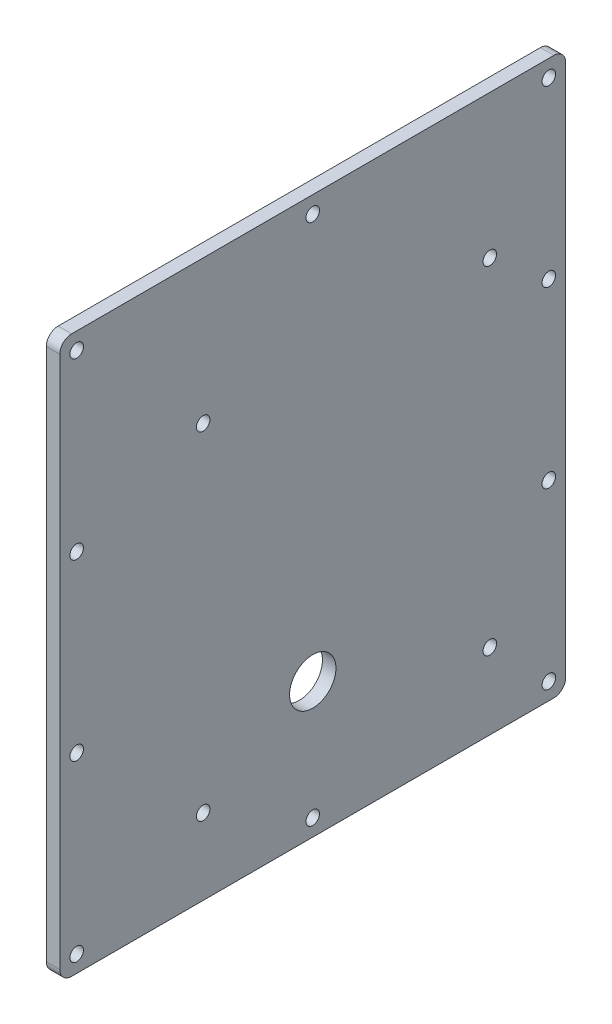
from build123d import *

# Parameters (mm, degrees)
SKETCH1_W              = 190.5
SKETCH1_H              = 209.55
BOSS_EXTRUDE2_DEPTH    = 5.08
SKETCH2_R              = 8.73125
CUT_EXTRUDE1_DEPTH     = 6.08
F_10_CLEARANCE_HOLE2_D = 5.1054
FILLET1_R              = 4.445
F_10_CLEARANCE_HOLE1_D = 5.1054


with BuildPart() as part:
    # Sketch1 → Boss-Extrude2 (new body)
    with BuildSketch(Plane(origin=(0, 0, 0), x_dir=(0, 0, -1), z_dir=(1, 0, 0))):
        with Locations((95.25, 104.775)):
            Rectangle(SKETCH1_W, SKETCH1_H)
    extrude(amount=BOSS_EXTRUDE2_DEPTH)

    # Sketch2 → Cut-Extrude1 (cut, through all)
    with BuildSketch(Plane(origin=(5.08, 0, 0), x_dir=(0, 0, -1), z_dir=(1, 0, 0))):
        with Locations((95.25, 50.8)):
            Circle(SKETCH2_R)
    extrude(amount=-CUT_EXTRUDE1_DEPTH, mode=Mode.SUBTRACT)

    # #10 Clearance Hole2 (through all)
    with Locations(Plane(origin=(5.08, 0, 0), x_dir=(0, 0, -1), z_dir=(1, 0, 0))):
        with Locations((53.975, 28.575), (53.975, 155.575), (161.925, 155.575), (161.925, 28.575)):
            Hole(F_10_CLEARANCE_HOLE2_D / 2)

    # Fillet1
    fillet1_edges = [part.edges().sort_by_distance(p)[0] for p in [
        (2.54, 209.55, 0),
        (2.54, 209.55, -190.5),
        (2.54, 0, -190.5),
        (2.54, 0, 0),
    ]]
    fillet(fillet1_edges, radius=FILLET1_R)

    # #10 Clearance Hole1 (through all)
    with Locations(Plane(origin=(5.08, 0, 0), x_dir=(0, 0, -1), z_dir=(1, 0, 0))):
        with Locations((6.35, 203.2), (184.15, 6.35), (6.35, 6.35), (184.15, 203.2), (95.25, 6.35), (95.25, 203.2), (6.35, 137.583333333), (6.35, 71.966666667), (184.15, 71.966666667), (184.15, 137.583333333)):
            Hole(F_10_CLEARANCE_HOLE1_D / 2)


solid = part.part
